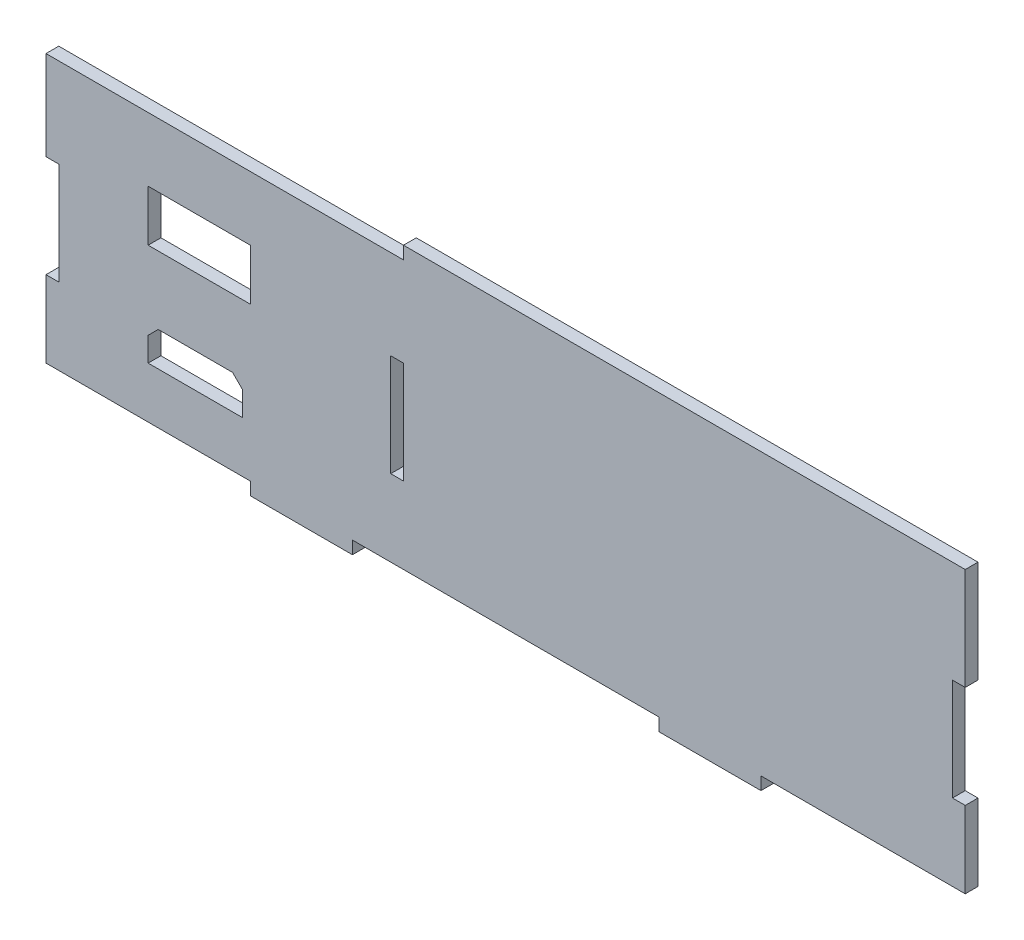
from build123d import *

# Parameters (mm, degrees)
SKETCH1_W           = 3.175
SKETCH1_H           = 25.4
BOSS_EXTRUDE1_DEPTH = 3.175
SKETCH2_W           = 25.4
SKETCH2_H           = 12.7
CUT_EXTRUDE1_DEPTH  = 4.175
SKETCH3_W           = 88.9
SKETCH3_H           = 3.175
CUT_EXTRUDE2_DEPTH  = 4.175


with BuildPart() as part:
    # Sketch1 → Boss-Extrude1 (new body)
    with BuildSketch(Plane.XY):
        Polygon((-114.3, 34.925), (-114.3, 9.525), (-111.125, 9.525), (-111.125, -15.875), (-114.3, -15.875), (-114.3, -34.925), (-63.5, -34.925), (-63.5, -38.1), (-38.1, -38.1), (-38.1, -34.925), (38.1, -34.925), (38.1, -38.1), (63.5, -38.1), (63.5, -34.925), (114.3, -34.925), (114.3, -15.875), (111.125, -15.875), (111.125, 9.525), (114.3, 9.525), (114.3, 34.925), align=None)
        with Locations((-26.9875, -3.175)):
            Rectangle(SKETCH1_W, SKETCH1_H, mode=Mode.SUBTRACT)
    extrude(amount=BOSS_EXTRUDE1_DEPTH)

    # Sketch2 → Cut-Extrude1 (cut, through all)
    with BuildSketch(Plane.XY.offset(3.175)):
        Polygon((-88.9, -16.225), (-86.4, -13.725), (-67.9, -13.725), (-65.4, -16.225), (-65.4, -22.225), (-88.9, -22.225), align=None)
        with Locations((-76.2, 9.525)):
            Rectangle(SKETCH2_W, SKETCH2_H)
    extrude(amount=-CUT_EXTRUDE1_DEPTH, mode=Mode.SUBTRACT)

    # Sketch3 → Cut-Extrude2 (cut, through all)
    with BuildSketch(Plane.XY.offset(3.175)):
        with Locations((-69.85, 33.3375)):
            Rectangle(SKETCH3_W, SKETCH3_H)
    extrude(amount=-CUT_EXTRUDE2_DEPTH, mode=Mode.SUBTRACT)


solid = part.part
